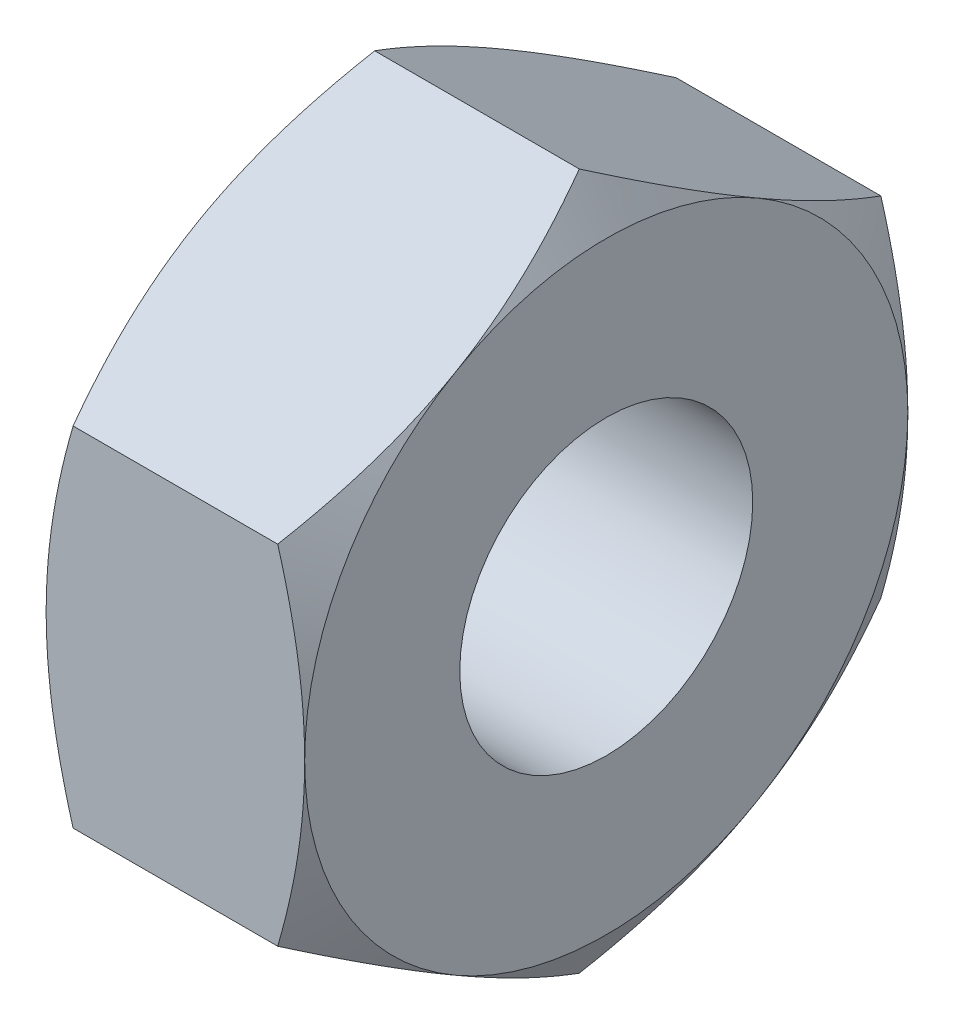
from build123d import *

# Parameters (mm, degrees)
ENL_V_MAT_EXTRU_1_DEPTH = 7
PER_AGE2_D              = 6.8
PER_AGE2_DEPTH          = 22.25
PER_AGE2_TIP            = 2.042926105


with BuildPart() as part:
    # Esquisse1 → Base-Révolution (revolve)
    with BuildSketch(Plane.XY, mode=Mode.PRIVATE) as base_r_volution_sk:
        Polygon((-3, 0), (3, 0), (3, 7), (0, 12.196152423), (-3, 7), align=None)
    revolve(base_r_volution_sk.sketch.rotate(Axis((-10.755568754, 0, 0), (1, 0, 0)), 270), axis=Axis((-10.755568754, 0, 0), (1, 0, 0)))  # turned: the seam where the file's is

    # Esquisse2 → Enlèv. mat.-Extru.1 (cut, through all)
    with BuildSketch(Plane.ZY.offset(3)):
        Polygon((0, 19.629909152), (17, 9.814954576), (17, -9.814954576), (0, -19.629909152), (-17, -9.814954576), (-17, 9.814954576), align=None)
        Polygon((0, 8.082903769), (7, 4.041451884), (7, -4.041451884), (0, -8.082903769), (-7, -4.041451884), (-7, 4.041451884), align=None, mode=Mode.SUBTRACT)
    extrude(amount=-ENL_V_MAT_EXTRU_1_DEPTH, mode=Mode.SUBTRACT)

    # Perçage2
    with Locations(Plane(origin=(3, 0, 0), x_dir=(0, 0, -1), z_dir=(1, 0, 0))):
        with Locations((0, 0)):
            Hole(PER_AGE2_D / 2, depth=PER_AGE2_DEPTH)
            with Locations((0, 0, -(PER_AGE2_DEPTH + PER_AGE2_TIP / 2))):  # 118° drill point
                Cone(0, PER_AGE2_D / 2, PER_AGE2_TIP, mode=Mode.SUBTRACT)


solid = part.part
